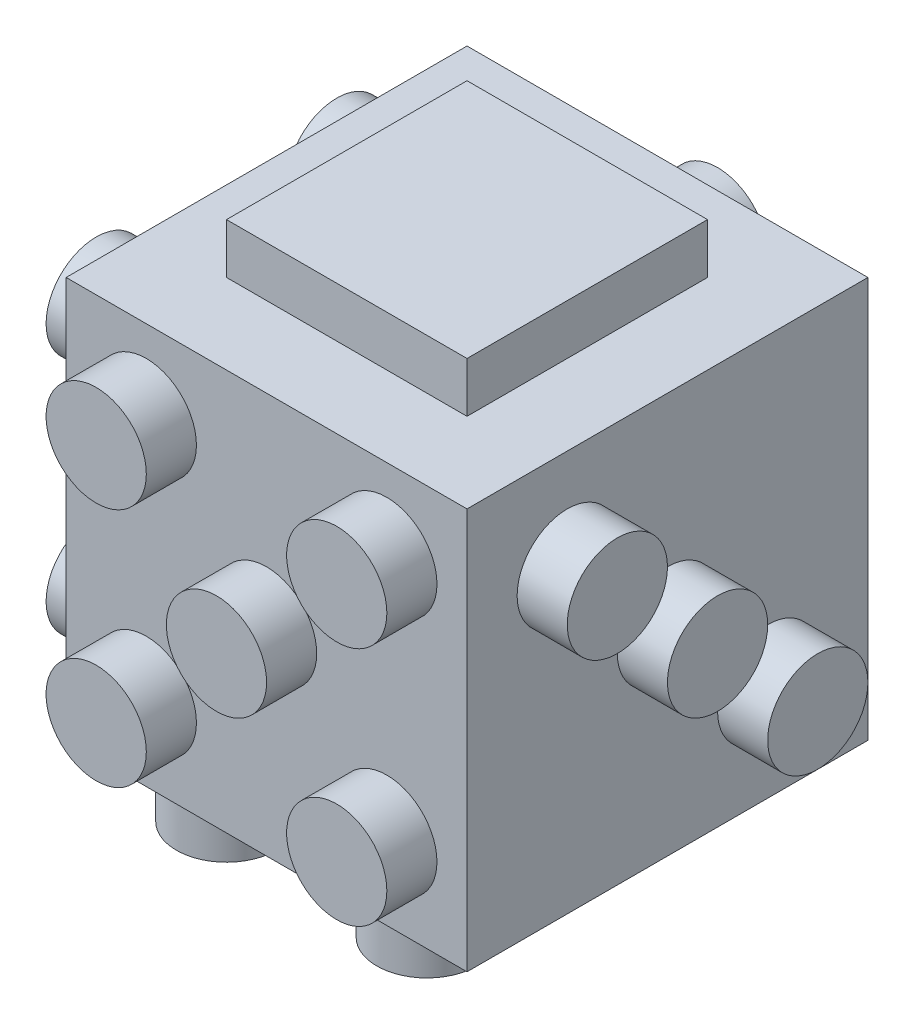
from build123d import *

# Parameters (mm, degrees)
SKETCH1_W             = 25
SKETCH1_H             = 25
BOSS_EXTRUDE1_DEPTH   = 25
SCALE1_SCALE          = 0.8
SKETCH3_R             = 2.5
BOSS_EXTRUDE2_DEPTH   = 2.5
BOSS_EXTRUDE2_2_DEPTH = 2.5
BOSS_EXTRUDE2_3_DEPTH = 2.5
BOSS_EXTRUDE2_4_DEPTH = 2.5
BOSS_EXTRUDE2_5_DEPTH = 2.5
BOSS_EXTRUDE2_6_DEPTH = 2.5
SKETCH7_R             = 2.5
BOSS_EXTRUDE3_DEPTH   = 2.5
SKETCH5_R             = 2.5
BOSS_EXTRUDE4_DEPTH   = 2.5
SKETCH4_R             = 2.5
BOSS_EXTRUDE5_DEPTH   = 2.5
SKETCH2_W             = 12
SKETCH2_H             = 12
BOSS_EXTRUDE7_DEPTH   = 2.5
SKETCH8_R             = 2.5
BOSS_EXTRUDE8_DEPTH   = 10


with BuildPart() as part:
    # Sketch1 → Boss-Extrude1 (new body)
    with BuildSketch(Plane(origin=(0, 0, 0), x_dir=(1, 0, 0), z_dir=(0, 1, 0))):
        Rectangle(SKETCH1_W, SKETCH1_H)
    extrude(amount=BOSS_EXTRUDE1_DEPTH)


with BuildPart() as part_1:
    # Scale1: scaled about (0, 12.5, 0)
    add(part.part.scale(SCALE1_SCALE).moved(Location((0, 2.5, 0))))

    # Sketch7 → Boss-Extrude3 (add)
    with BuildSketch(Plane.XY.offset(12.5)):
        with Locations((-6, 18.5)):
            Circle(SKETCH7_R)
        with Locations((0, 12.5)):
            Circle(SKETCH7_R)
        with Locations((6, 18.5)):
            Circle(SKETCH7_R)
        with Locations((6, 6.5)):
            Circle(SKETCH7_R)
        with Locations((-6, 6.5)):
            Circle(SKETCH7_R)
    extrude(amount=-BOSS_EXTRUDE3_DEPTH)

    # Sketch5 → Boss-Extrude4 (add)
    with BuildSketch(Plane.ZY.offset(12.5)):
        with Locations((-6, 18.5)):
            Circle(SKETCH5_R)
        with Locations((6, 18.5)):
            Circle(SKETCH5_R)
        with Locations((6, 6.5)):
            Circle(SKETCH5_R)
        with Locations((-6, 6.5)):
            Circle(SKETCH5_R)
    extrude(amount=-BOSS_EXTRUDE4_DEPTH)

    # Sketch4 → Boss-Extrude5 (add)
    with BuildSketch(Plane(origin=(12.5, 0, 0), x_dir=(0, 0, -1), z_dir=(1, 0, 0))):
        with Locations((-5, 17.5)):
            Circle(SKETCH4_R)
        with Locations((0, 12.5)):
            Circle(SKETCH4_R)
        with Locations((5, 7.5)):
            Circle(SKETCH4_R)
    extrude(amount=-BOSS_EXTRUDE5_DEPTH)

    # Sketch2 → Boss-Extrude7 (add)
    with BuildSketch(Plane(origin=(0, 25, 0), x_dir=(1, 0, 0), z_dir=(0, 1, 0))):
        Rectangle(SKETCH2_W, SKETCH2_H)
    extrude(amount=-BOSS_EXTRUDE7_DEPTH)

    # Sketch8 → Boss-Extrude8 (add)
    with BuildSketch(Plane(origin=(0, 0, -12.5), x_dir=(-1, 0, 0), z_dir=(0, 0, -1))):
        with Locations((0, 6.5)):
            Circle(SKETCH8_R)
        with Locations((0, 18.5)):
            Circle(SKETCH8_R)
    extrude(amount=-BOSS_EXTRUDE8_DEPTH)


with BuildPart() as body_2:
    # Sketch3 → Boss-Extrude2 (new body)
    with BuildSketch(Plane.XZ):
        with Locations((-5, 7)):
            Circle(SKETCH3_R)
    extrude(amount=-BOSS_EXTRUDE2_DEPTH)


with BuildPart() as body_3:
    # Sketch3 → Boss-Extrude2 2 (new body)
    with BuildSketch(Plane.XZ):
        with Locations((-5, 0)):
            Circle(SKETCH3_R)
    extrude(amount=-BOSS_EXTRUDE2_2_DEPTH)


with BuildPart() as body_4:
    # Sketch3 → Boss-Extrude2 3 (new body)
    with BuildSketch(Plane.XZ):
        with Locations((-5, -7)):
            Circle(SKETCH3_R)
    extrude(amount=-BOSS_EXTRUDE2_3_DEPTH)


with BuildPart() as body_5:
    # Sketch3 → Boss-Extrude2 4 (new body)
    with BuildSketch(Plane.XZ):
        with Locations((5, 7)):
            Circle(SKETCH3_R)
    extrude(amount=-BOSS_EXTRUDE2_4_DEPTH)


with BuildPart() as body_6:
    # Sketch3 → Boss-Extrude2 5 (new body)
    with BuildSketch(Plane.XZ):
        with Locations((5, 0)):
            Circle(SKETCH3_R)
    extrude(amount=-BOSS_EXTRUDE2_5_DEPTH)


with BuildPart() as body_7:
    # Sketch3 → Boss-Extrude2 6 (new body)
    with BuildSketch(Plane.XZ):
        with Locations((5, -7)):
            Circle(SKETCH3_R)
    extrude(amount=-BOSS_EXTRUDE2_6_DEPTH)


solid = Compound([part_1.part, body_2.part, body_3.part, body_4.part, body_5.part, body_6.part, body_7.part])
